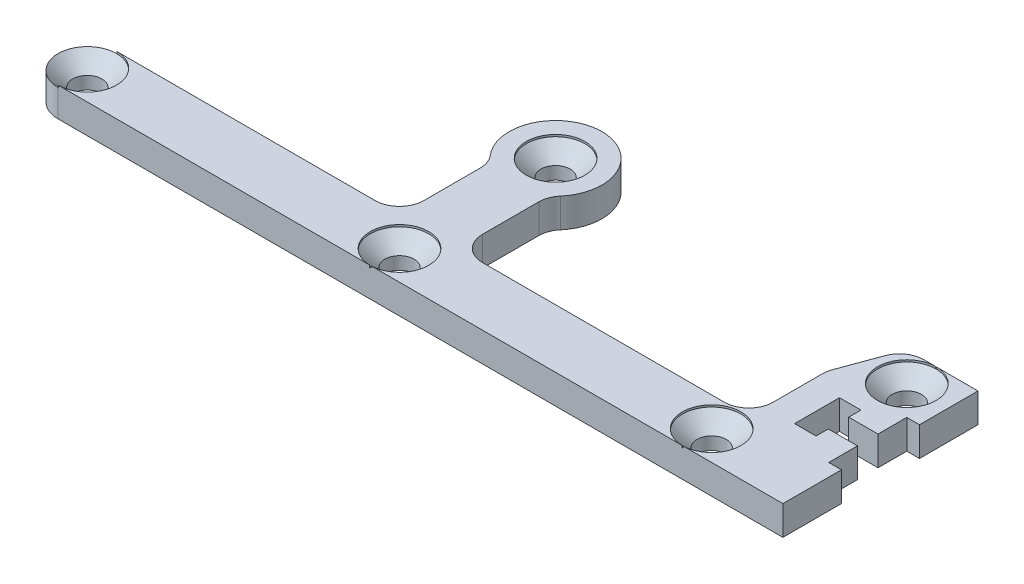
from build123d import *

# Parameters (mm, degrees)
SKETCH1_R                                      = 1.5
BOSS_EXTRUDE1_DEPTH                            = 3
FILLET1_R                                      = 2.5
CSK_FOR_M3_FLAT_HEAD_MACHINE_SCREW3_AT_2_COUNT = 2
CSK_FOR_M3_FLAT_HEAD_MACHINE_SCREW3_AT_2_PITCH = 32
CSK_FOR_M3_FLAT_HEAD_MACHINE_SCREW3_AT_3_COUNT = 2
CSK_FOR_M3_FLAT_HEAD_MACHINE_SCREW3_AT_3_PITCH = 71.38627319
CSK_FOR_M3_FLAT_HEAD_MACHINE_SCREW3_AT_4_COUNT = 2
CSK_FOR_M3_FLAT_HEAD_MACHINE_SCREW3_AT_4_PITCH = 35.77708764
CSK_FOR_M3_FLAT_HEAD_MACHINE_SCREW3_AT_5_COUNT = 2
CSK_FOR_M3_FLAT_HEAD_MACHINE_SCREW3_AT_5_PITCH = 64


with BuildPart() as part:
    # Sketch1 → Boss-Extrude1 (new body)
    with BuildSketch(Plane(origin=(0, 0, 0), x_dir=(1, 0, 0), z_dir=(0, 1, 0))):
        with BuildLine():
            Line((-3, -13), (-32, -13))
            ThreePointArc((-32, -13), (-35, -16), (-32, -19))
            Line((-32, -19), (42.3, -19))
            Line((42.3, -19), (42.3, -13))
            Line((42.3, -13), (41, -13))
            Line((41, -13), (41, -10.05))
            Line((41, -10.05), (38, -10.05))
            Line((38, -10.05), (38, -11.3))
            Line((38, -11.3), (35.8, -11.3))
            Line((35.8, -11.3), (35.8, -6.7))
            Line((35.8, -6.7), (38, -6.7))
            Line((38, -6.7), (38, -7.95))
            Line((38, -7.95), (41, -7.95))
            Line((41, -7.95), (41, -5))
            Line((41, -5), (42.3, -5))
            Line((42.3, -5), (42.3, 1))
            Line((42.3, 1), (35, 1))
            Line((35, 1), (32.8, -5))
            Line((32.8, -5), (32.8, -13))
            Line((32.8, -13), (3, -13))
            Line((3, -13), (3, -3.682729966))
            ThreePointArc((3, -3.682729966), (0, 4.75), (-3, -3.682729966))
            Line((-3, -3.682729966), (-3, -13))
        make_face()
        with Locations((32, -16)):
            Circle(SKETCH1_R, mode=Mode.SUBTRACT)
        with Locations((0, -16)):
            Circle(SKETCH1_R, mode=Mode.SUBTRACT)
        with Locations((-32, -16)):
            Circle(SKETCH1_R, mode=Mode.SUBTRACT)
        Circle(SKETCH1_R, mode=Mode.SUBTRACT)
        with Locations((38, -2)):
            Circle(SKETCH1_R, mode=Mode.SUBTRACT)
    extrude(amount=BOSS_EXTRUDE1_DEPTH)

    # Fillet1
    fillet1_edges = [part.edges().sort_by_distance(p)[0] for p in [
        (35, 1.5, -1),
        (32.8, 1.5, 5),
        (32.8, 1.5, 13),
        (3, 1.5, 13),
        (-3, 1.5, 13),
        (-3, 1.5, 3.682729966),
        (3, 1.5, 3.682729966),
    ]]
    fillet(fillet1_edges, radius=FILLET1_R)

    # Sketch5 → CSK for M3 Flat Head Machine Screw3 (revolve, cut)
    with BuildSketch(Plane(origin=(-32, 3, 16), x_dir=(0, 0, 1), z_dir=(1, 0, 0))):
        Polygon((0, 0), (0, 3), (1.5, 3), (1.5, 1.7005), (3.0005, 0.2), (3.0005, 0), align=None)
    csk_for_m3_flat_head_machine_screw3 = revolve(axis=Axis((-32, 9.35, 16), (0, -1, 0)), mode=Mode.SUBTRACT)

    # CSK for M3 Flat Head Machine Screw3 at 2: CSK for M3 Flat Head Machine Screw3 ×2
    with Locations(*[(i * CSK_FOR_M3_FLAT_HEAD_MACHINE_SCREW3_AT_2_PITCH, 0, 0) for i in range(1, CSK_FOR_M3_FLAT_HEAD_MACHINE_SCREW3_AT_2_COUNT)]):
        add(csk_for_m3_flat_head_machine_screw3, mode=Mode.SUBTRACT)

    # CSK for M3 Flat Head Machine Screw3 at 3: CSK for M3 Flat Head Machine Screw3 ×2
    with Locations(*[Vector(0.9805806756909202, 0, -0.1961161351381841) * (i * CSK_FOR_M3_FLAT_HEAD_MACHINE_SCREW3_AT_3_PITCH) for i in range(1, CSK_FOR_M3_FLAT_HEAD_MACHINE_SCREW3_AT_3_COUNT)]):
        add(csk_for_m3_flat_head_machine_screw3, mode=Mode.SUBTRACT)

    # CSK for M3 Flat Head Machine Screw3 at 4: CSK for M3 Flat Head Machine Screw3 ×2
    with Locations(*[Vector(0.8944271909999157, 0, -0.44721359549995826) * (i * CSK_FOR_M3_FLAT_HEAD_MACHINE_SCREW3_AT_4_PITCH) for i in range(1, CSK_FOR_M3_FLAT_HEAD_MACHINE_SCREW3_AT_4_COUNT)]):
        add(csk_for_m3_flat_head_machine_screw3, mode=Mode.SUBTRACT)

    # CSK for M3 Flat Head Machine Screw3 at 5: CSK for M3 Flat Head Machine Screw3 ×2
    with Locations(*[(i * CSK_FOR_M3_FLAT_HEAD_MACHINE_SCREW3_AT_5_PITCH, 0, 0) for i in range(1, CSK_FOR_M3_FLAT_HEAD_MACHINE_SCREW3_AT_5_COUNT)]):
        add(csk_for_m3_flat_head_machine_screw3, mode=Mode.SUBTRACT)


solid = part.part
